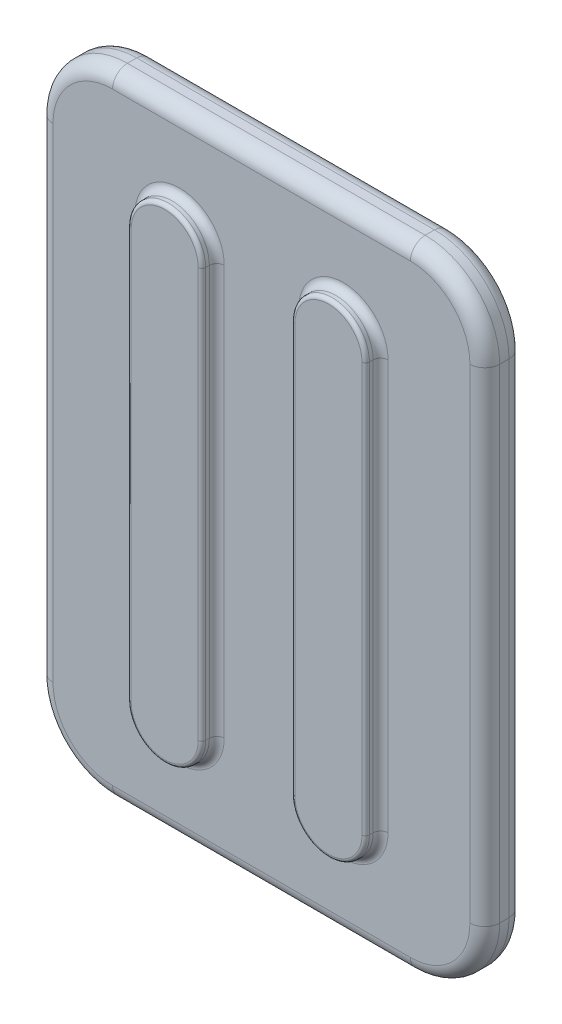
from build123d import *

# Parameters (mm, degrees)
SKETCH_1_W      = 600
SKETCH_1_H      = 850
EXTRUDE_1_DEPTH = 52.484908593
EXTRUDE_2_DEPTH = 20
FILLET_1_R      = 100
FILLET_2_R      = 10
FILLET_3_R      = 5
FILLET_4_R      = 20
EXTRUDE_START   = -100
EXTRUDE_3_DEPTH = 670


with BuildPart() as part:
    # 草图1 → 凸台-拉伸1 (new body)
    with BuildSketch(Plane.XY):
        Rectangle(SKETCH_1_W, SKETCH_1_H)
    extrude(amount=EXTRUDE_1_DEPTH)

    # 草图2 → 凸台-拉伸2 (add)
    with BuildSketch(Plane.XY.offset(52.484908593)):
        with BuildLine():
            Line((-60, 275), (-60, -275))
            ThreePointArc((-60, -275), (-110, -325), (-160, -275))
            Line((-160, -275), (-160, 275))
            ThreePointArc((-160, 275), (-110, 325), (-60, 275))
        make_face()
        with BuildLine():
            Line((60, 275), (60, -275))
            ThreePointArc((60, -275), (110, -325), (160, -275))
            Line((160, -275), (160, 275))
            ThreePointArc((160, 275), (110, 325), (60, 275))
        make_face()
    extrude(amount=EXTRUDE_2_DEPTH)

    # 圆角1
    fillet_1_edges = [part.edges().sort_by_distance(p)[0] for p in [
        (300, -425, 26.242454296),
        (-300, -425, 26.242454296),
        (-300, 425, 26.242454296),
        (300, 425, 26.242454296),
    ]]
    fillet(fillet_1_edges, radius=FILLET_1_R)

    # 圆角2
    fillet_2_edges = [part.edges().sort_by_distance(p)[0] for p in [
        (-110, 325, 52.484908593),
        (-160, 0, 52.484908593),
        (-110, -325, 52.484908593),
        (-60, 0, 52.484908593),
        (110, 325, 52.484908593),
        (60, 0, 52.484908593),
        (110, -325, 52.484908593),
        (160, 0, 52.484908593),
    ]]
    fillet(fillet_2_edges, radius=FILLET_2_R)

    # 圆角3
    fillet_3_edges = [part.edges().sort_by_distance(p)[0] for p in [
        (-110, 325, 72.484908593),
        (-160, 0, 72.484908593),
        (-110, -325, 72.484908593),
        (-60, 0, 72.484908593),
        (110, 325, 72.484908593),
        (60, 0, 72.484908593),
        (110, -325, 72.484908593),
        (160, 0, 72.484908593),
    ]]
    fillet(fillet_3_edges, radius=FILLET_3_R)

    # 圆角4
    fillet_4_edges = [part.edges().sort_by_distance(p)[0] for p in [
        (0, 425, 0),
        (0, 425, 52.484908593),
        (300, 0, 0),
        (0, -425, 0),
        (-300, 0, 0),
        (-270.710678119, -395.710678119, 0),
        (270.710678119, -395.710678119, 0),
        (-270.710678119, 395.710678119, 0),
        (270.710678119, 395.710678119, 0),
        (300, 0, 52.484908593),
        (-300, 0, 52.484908593),
        (0, -425, 52.484908593),
        (-270.710678119, -395.710678119, 52.484908593),
        (270.710678119, -395.710678119, 52.484908593),
        (-270.710678119, 395.710678119, 52.484908593),
        (270.710678119, 395.710678119, 52.484908593),
    ]]
    fillet(fillet_4_edges, radius=FILLET_4_R)

    # 草图3 → 凸台-拉伸3 (add)
    with BuildSketch(Plane(origin=(0, 425, 0), x_dir=(1, 0, 0), z_dir=(0, 1, 0)).offset(EXTRUDE_START)):
        Polygon((-159.75, 0), (-110.25, 0), (-110.25, 7.38), (-122.225, 19.39), (-147.775, 19.39), (-159.75, 7.38), align=None)
        Polygon((159.75, 0), (159.75, 7.38), (147.775, 19.39), (122.225, 19.39), (110.25, 7.38), (110.25, 0), align=None)
    extrude(amount=-EXTRUDE_3_DEPTH)


solid = part.part
